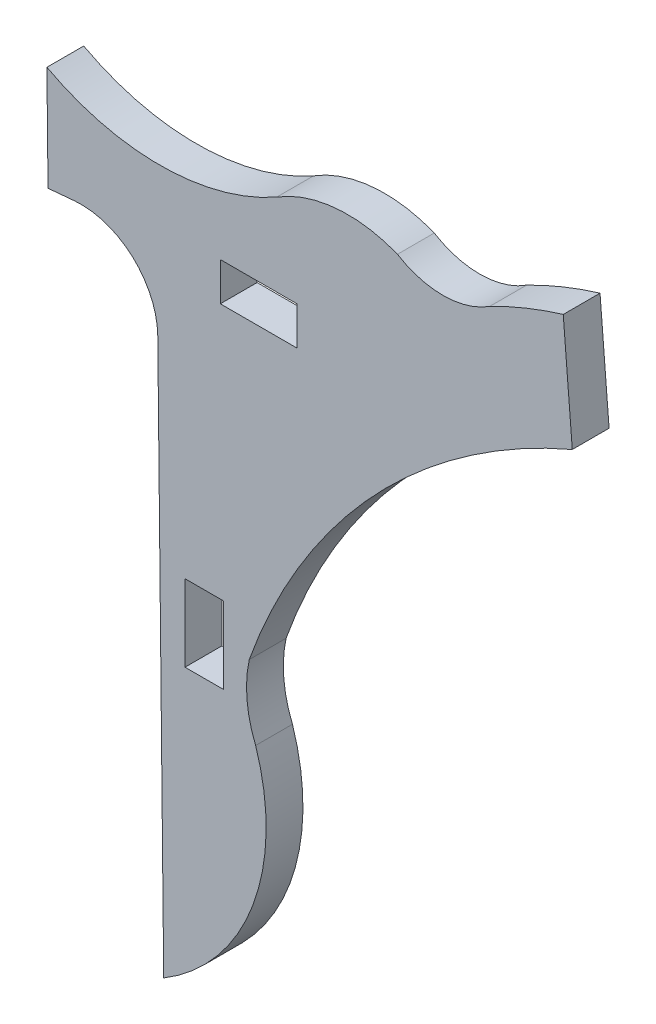
from build123d import *

# Parameters (mm, degrees)
SKETCH1_W           = 1.5875
SKETCH1_H           = 3.175
SKETCH1_W_2         = 3.175
SKETCH1_H_2         = 1.5875
BOSS_EXTRUDE1_DEPTH = 1.524


with BuildPart() as part:
    # Sketch1 → Boss-Extrude1 (new body)
    with BuildSketch(Plane.XY):
        with BuildLine():
            ThreePointArc((-92.462594244, 53.392882958), (-87.259455285, 61.89953001), (-79.086960783, 67.613200697))
            Line((-79.086960783, 67.613200697), (-79.461877647, 72.269382522))
            ThreePointArc((-79.461877647, 72.269382522), (-81.010669369, 71.722343201), (-82.50335439, 71.03685123))
            ThreePointArc((-82.50335439, 71.03685123), (-84.40835406, 70.46229139), (-86.325241021, 70.995852197))
            ThreePointArc((-86.325241021, 70.995852197), (-88.879114534, 71.369944183), (-91.324996548, 70.545398299))
            ThreePointArc((-91.324996548, 70.545398299), (-93.73568856, 69.57630413), (-96.315834525, 69.270646985))
            ThreePointArc((-96.315834525, 69.270646985), (-98.648749132, 69.584935579), (-100.840653449, 70.443319727))
            Line((-100.840653449, 70.443319727), (-100.794339098, 66.125944717))
            Line((-100.794339098, 66.125944717), (-99.710350028, 66.223965922))
            ThreePointArc((-99.710350028, 66.223965922), (-97.295430394, 65.417299389), (-96.249595613, 63.095925369))
            Line((-96.249595613, 63.095925369), (-96.004020182, 40.203642412))
            ThreePointArc((-96.004020182, 40.203642412), (-92.311993967, 44.659081136), (-92.198099781, 50.444322695))
            ThreePointArc((-92.198099781, 50.444322695), (-92.555911633, 51.898369022), (-92.462594244, 53.392882958))
        make_face()
        with Locations((-94.329440184, 53.37562941)):
            Rectangle(SKETCH1_W, SKETCH1_H, mode=Mode.SUBTRACT)
        with Locations((-92.073197515, 66.344715332)):
            Rectangle(SKETCH1_W_2, SKETCH1_H_2, mode=Mode.SUBTRACT)
    extrude(amount=BOSS_EXTRUDE1_DEPTH)


solid = part.part
